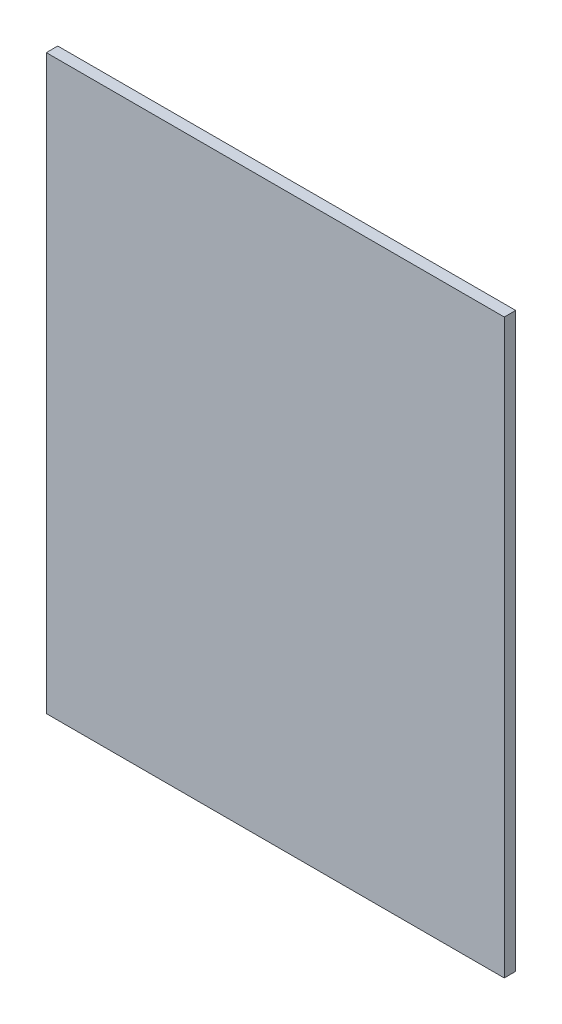
from build123d import *

# Parameters (mm, degrees)
SKETCH1_W           = 120
SKETCH1_H           = 150
BOSS_EXTRUDE1_DEPTH = 3


with BuildPart() as part:
    # Sketch1 → Boss-Extrude1 (new body)
    with BuildSketch(Plane.XY):
        with Locations((60, 75)):
            Rectangle(SKETCH1_W, SKETCH1_H)
    extrude(amount=BOSS_EXTRUDE1_DEPTH)


solid = part.part
